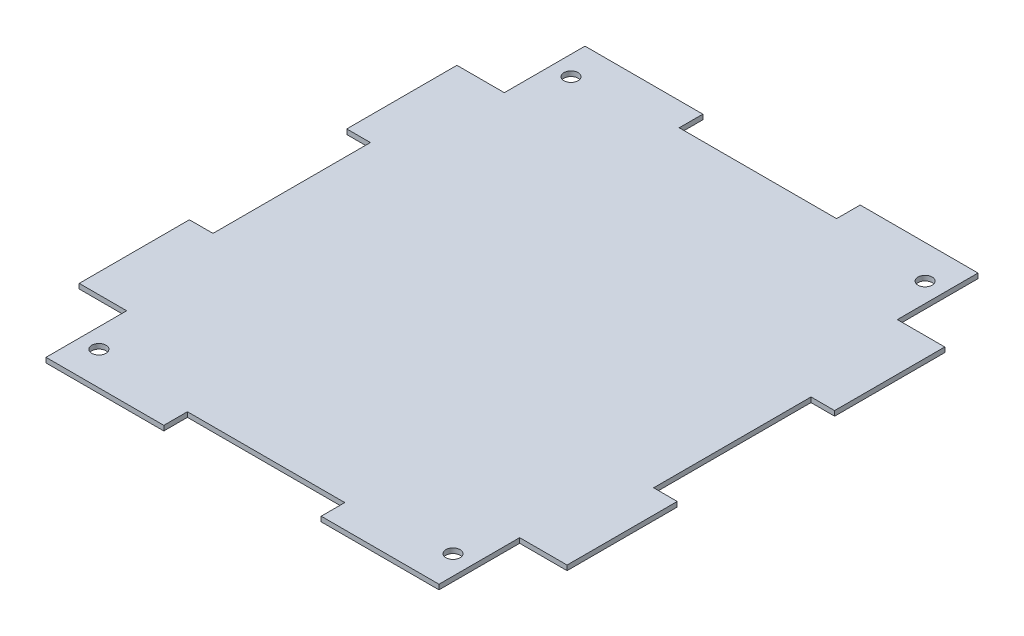
from build123d import *

# Parameters (mm, degrees)
SKETCH1_R       = 2.286
MAIN_BODY_DEPTH = 1.5875


with BuildPart() as part:
    # Sketch1 → Main Body (new body)
    with BuildSketch(Plane(origin=(0, 0, 0), x_dir=(1, 0, 0), z_dir=(0, 1, 0))):
        Polygon((-25.4, 86.995), (-63.43142, 86.995), (-63.43142, 60.96), (-78.74, 60.96), (-78.74, 25.4), (-71.12, 25.4), (-71.12, -25.4), (-78.74, -25.4), (-78.74, -60.96), (-63.43142, -60.96), (-63.43142, -86.995), (-25.4, -86.995), (-25.4, -79.375), (25.4, -79.375), (25.4, -86.995), (63.43142, -86.995), (63.43142, -60.96), (78.74, -60.96), (78.74, -25.4), (71.12, -25.4), (71.12, 25.4), (78.74, 25.4), (78.74, 60.96), (63.43142, 60.96), (63.43142, 86.995), (25.4, 86.995), (25.4, 79.375), (-25.4, 79.375), align=None)
        with Locations((-57.15, 76.2)):
            Circle(SKETCH1_R, mode=Mode.SUBTRACT)
        with Locations((57.15, 76.2)):
            Circle(SKETCH1_R, mode=Mode.SUBTRACT)
        with Locations((57.15, -76.2)):
            Circle(SKETCH1_R, mode=Mode.SUBTRACT)
        with Locations((-57.15, -76.2)):
            Circle(SKETCH1_R, mode=Mode.SUBTRACT)
    extrude(amount=MAIN_BODY_DEPTH)


solid = part.part
